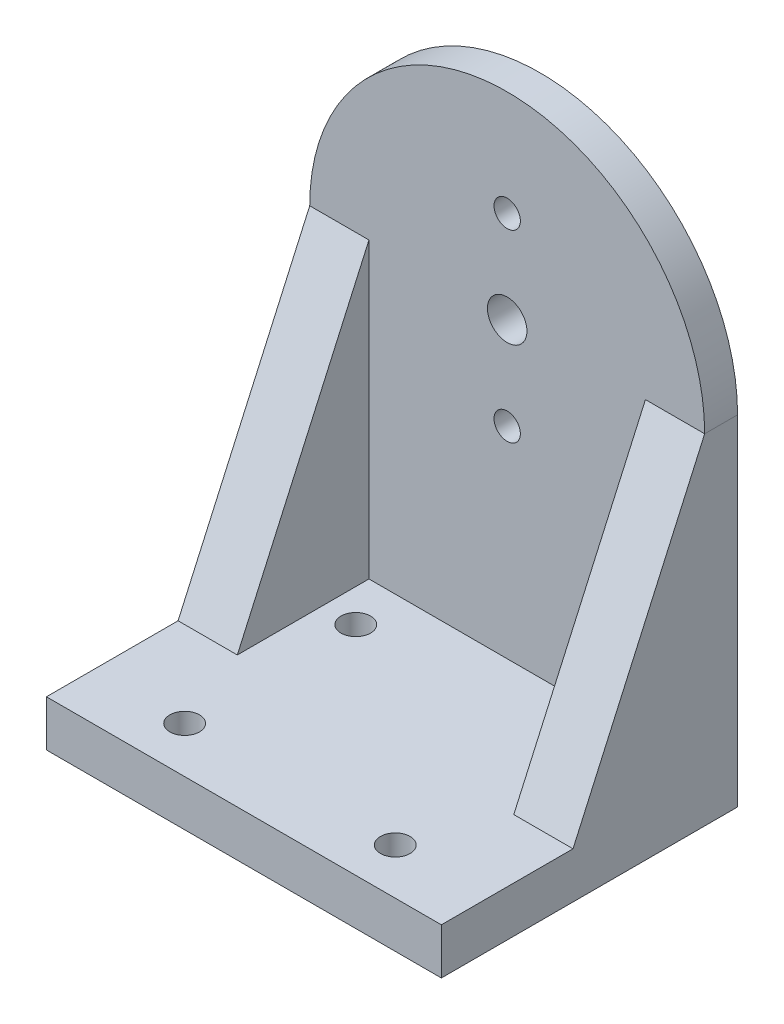
from build123d import *

# Parameters (mm, degrees)
SKETCH1_R           = 3
SKETCH1_R_2         = 2
BOSS_EXTRUDE1_DEPTH = 5
SKETCH2_W           = 60
SKETCH2_H           = 7
BOSS_EXTRUDE2_DEPTH = 40
BOSS_EXTRUDE3_DEPTH = 9
SKETCH4_R           = 2.25
CUT_EXTRUDE1_DEPTH  = 8


with BuildPart() as part:
    # Sketch1 → Boss-Extrude1 (new body)
    with BuildSketch(Plane.XY):
        with BuildLine():
            Line((-30, 26.6), (-30, -25))
            Line((-30, -25), (30, -25))
            Line((30, -25), (30, 26.6))
            ThreePointArc((30, 26.6), (0, 56.6), (-30, 26.6))
        make_face()
        with Locations((0, 26.6)):
            Circle(SKETCH1_R, mode=Mode.SUBTRACT)
        with Locations((0, 40.6)):
            Circle(SKETCH1_R_2, mode=Mode.SUBTRACT)
        with Locations((0, 12.6)):
            Circle(SKETCH1_R_2, mode=Mode.SUBTRACT)
    extrude(amount=BOSS_EXTRUDE1_DEPTH)

    # Sketch2 → Boss-Extrude2 (add)
    with BuildSketch(Plane.XY.offset(5)):
        with Locations((0, -21.5)):
            Rectangle(SKETCH2_W, SKETCH2_H)
    extrude(amount=BOSS_EXTRUDE2_DEPTH)

    # Sketch3 → Boss-Extrude3 (add)
    with BuildSketch(Plane.ZY.offset(30)):
        Polygon((5, 26.6), (25, -18), (5, -18), align=None)
    boss_extrude3 = extrude(amount=-BOSS_EXTRUDE3_DEPTH)

    # Mirror1: Boss-Extrude3 across plane
    add(boss_extrude3.mirror(Plane(origin=(0, 0, 0), x_dir=(0, 0, 1), z_dir=(1, 0, 0))))

    # Sketch4 → Cut-Extrude1 (cut, through all)
    with BuildSketch(Plane(origin=(0, -18, 0), x_dir=(1, 0, 0), z_dir=(0, 1, 0))):
        with Locations(Location((16, -38, 0), (0, 0, 270))):  # turned: the seam where the file's is
            Circle(SKETCH4_R)
        with Locations(Location((-16, -38, 0), (0, 0, 270))):  # turned: the seam where the file's is
            Circle(SKETCH4_R)
        with Locations(Location((-16, -12, 0), (0, 0, 270))):  # turned: the seam where the file's is
            Circle(SKETCH4_R)
        with Locations(Location((16, -12, 0), (0, 0, 270))):  # turned: the seam where the file's is
            Circle(SKETCH4_R)
    extrude(amount=-CUT_EXTRUDE1_DEPTH, mode=Mode.SUBTRACT)


solid = part.part
